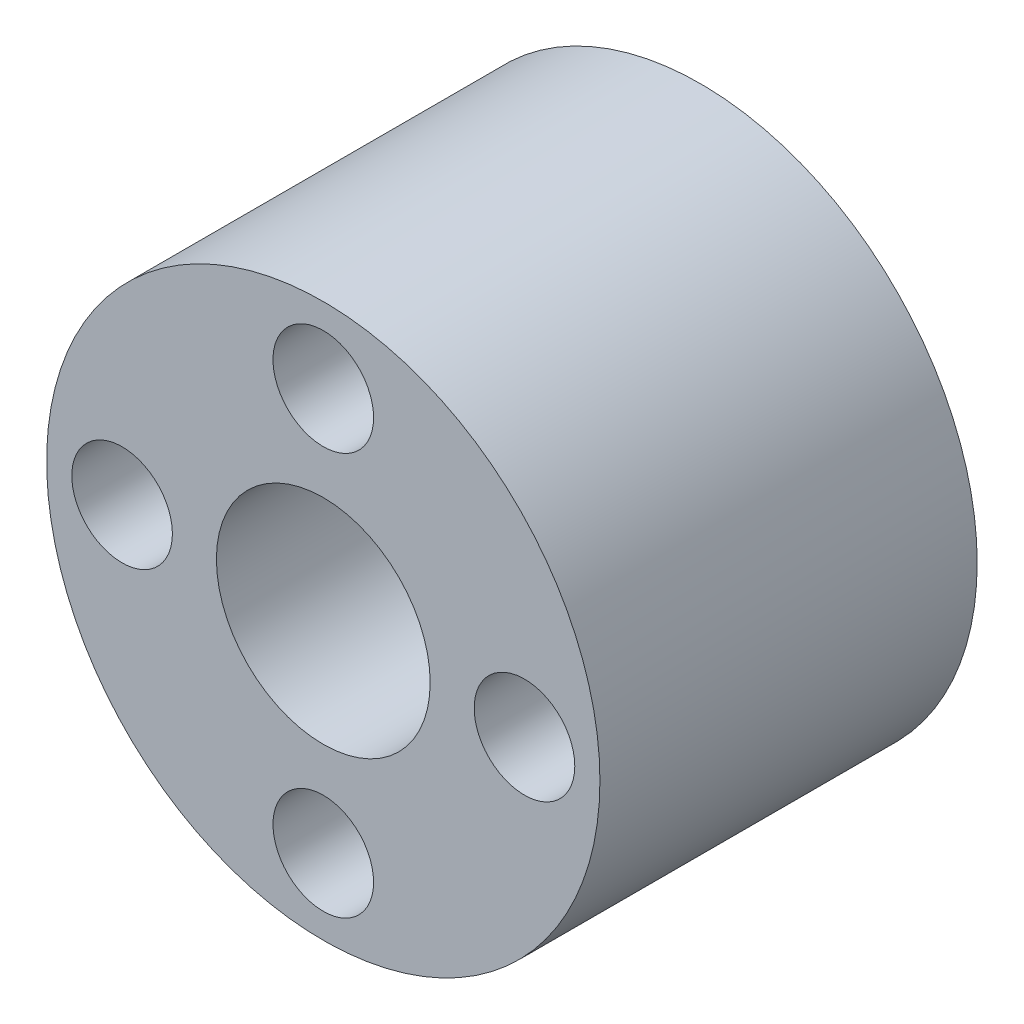
from build123d import *

# Parameters (mm, degrees)
SKETCH1_R           = 11
BOSS_EXTRUDE1_DEPTH = 15
SKETCH3_R           = 2
CUT_EXTRUDE1_DEPTH  = 15
SKETCH4_R           = 4.25
CUT_EXTRUDE2_DEPTH  = 10


with BuildPart() as part:
    # Sketch1 → Boss-Extrude1 (new body)
    with BuildSketch(Plane.XY):
        Circle(SKETCH1_R)
    extrude(amount=BOSS_EXTRUDE1_DEPTH)

    # Sketch3 → Cut-Extrude1 (cut)
    with BuildSketch(Plane.XY.offset(15)):
        with Locations((-8, 0)):
            Circle(SKETCH3_R)
        with Locations((0, 8)):
            Circle(SKETCH3_R)
        with Locations((8, 0)):
            Circle(SKETCH3_R)
        with Locations((0, -8)):
            Circle(SKETCH3_R)
    extrude(amount=-CUT_EXTRUDE1_DEPTH, mode=Mode.SUBTRACT)

    # Sketch4 → Cut-Extrude2 (cut)
    with BuildSketch(Plane.XY.offset(15)):
        Circle(SKETCH4_R)
    extrude(amount=-CUT_EXTRUDE2_DEPTH, mode=Mode.SUBTRACT)


solid = part.part
